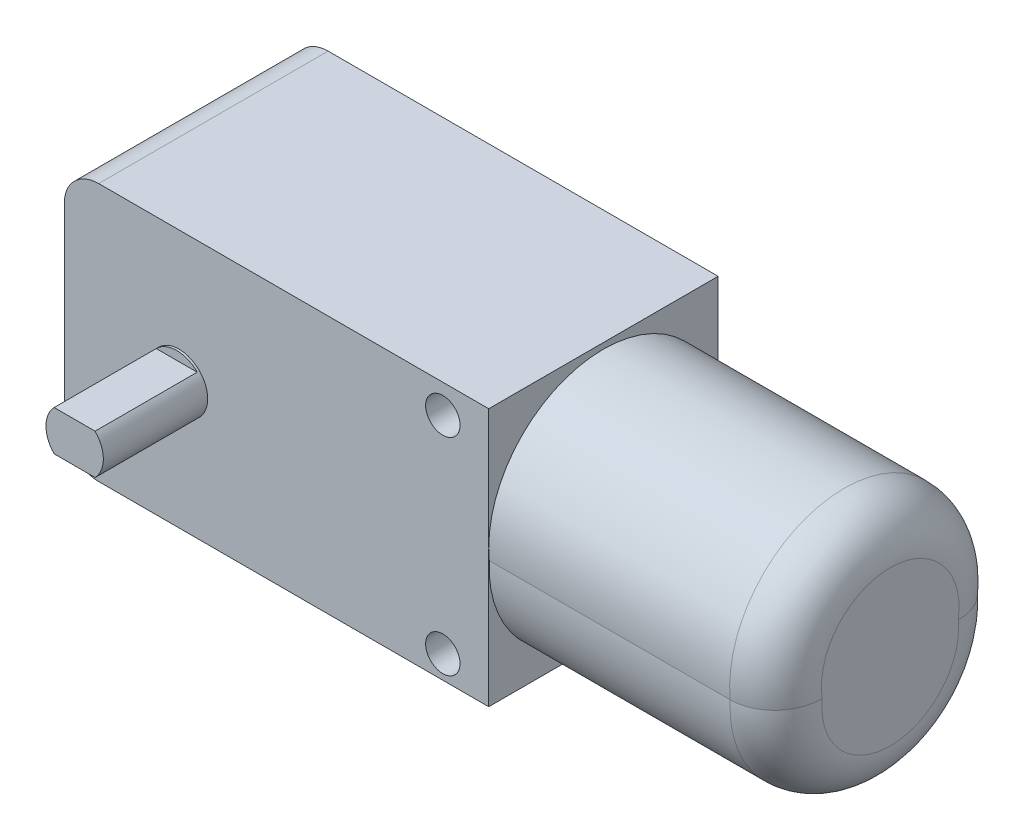
from build123d import *

# Parameters (mm, degrees)
SKETCH1_W           = 37
SKETCH1_H           = 22.5
BOSS_EXTRUDE1_DEPTH = 20
BOSS_EXTRUDE2_DEPTH = 25
SKETCH3_R           = 2.5
BOSS_EXTRUDE3_DEPTH = 9.1
SKETCH4_R           = 2.5
BOSS_EXTRUDE4_DEPTH = 9.1
FILLET1_R           = 3
FILLET2_R           = 4
SKETCH5_W           = 2.75
SKETCH5_H           = 5
BOSS_EXTRUDE5_DEPTH = 5
SKETCH6_R           = 1.5
CUT_EXTRUDE1_DEPTH  = 2.75
SKETCH7_R           = 1.5
CUT_EXTRUDE2_DEPTH  = 30.1
SKETCH8_W           = 8.509980697
SKETCH8_H           = 2.764975678
SKETCH8_W_2         = 9.677414873
SKETCH8_H_2         = 2.427034206
CUT_EXTRUDE3_DEPTH  = 8.9
SKETCH9_W           = 9.677414873
SKETCH9_H           = 2.427034206
SKETCH9_W_2         = 8.509980697
SKETCH9_H_2         = 2.764975678
CUT_EXTRUDE4_DEPTH  = 8.9


with BuildPart() as part:
    # Sketch1 → Boss-Extrude1 (new body)
    with BuildSketch(Plane.XY):
        with Locations((-45.764100782, -13.75)):
            Rectangle(SKETCH1_W, SKETCH1_H)
    extrude(amount=-BOSS_EXTRUDE1_DEPTH)

    # Sketch2 → Boss-Extrude2 (add)
    with BuildSketch(Plane(origin=(-27.264100782, 0, 0), x_dir=(0, 0, -1), z_dir=(1, 0, 0))):
        with BuildLine():
            ThreePointArc((0.050125629, -14), (10, -24.462429423), (19.949874371, -14))
            ThreePointArc((19.949874371, -14), (10, -3), (0.050125629, -14))
        make_face()
    extrude(amount=BOSS_EXTRUDE2_DEPTH)

    # Sketch3 → Boss-Extrude3 (add)
    with BuildSketch(Plane.XY):
        with Locations((-54.264100782, -14)):
            Circle(SKETCH3_R)
    extrude(amount=BOSS_EXTRUDE3_DEPTH)

    # Sketch4 → Boss-Extrude4 (add)
    with BuildSketch(Plane(origin=(0, 0, -20), x_dir=(-1, 0, 0), z_dir=(0, 0, -1))):
        with Locations((54.264100782, -14)):
            Circle(SKETCH4_R)
    extrude(amount=BOSS_EXTRUDE4_DEPTH)

    # Fillet1
    fillet1_edges = [part.edges().sort_by_distance(p)[0] for p in [
        (-64.264100782, -2.5, -10),
        (-64.264100782, -25, -10),
    ]]
    fillet(fillet1_edges, radius=FILLET1_R)

    # Fillet2
    fillet2_edges = [part.edges().sort_by_distance(p)[0] for p in [
        (-2.264100782, -3, -10),
        (-2.264100782, -24.462429423, -10),
    ]]
    fillet(fillet2_edges, radius=FILLET2_R)

    # Sketch5 → Boss-Extrude5 (add)
    with BuildSketch(Plane.ZY.offset(64.264100782)):
        with Locations((-10, -13.75)):
            Rectangle(SKETCH5_W, SKETCH5_H)
    extrude(amount=BOSS_EXTRUDE5_DEPTH)

    # Sketch6 → Cut-Extrude1 (cut)
    with BuildSketch(Plane(origin=(0, 0, -11.375), x_dir=(-1, 0, 0), z_dir=(0, 0, -1))):
        with Locations((66.764100782, -13.75)):
            Circle(SKETCH6_R)
    extrude(amount=-CUT_EXTRUDE1_DEPTH, mode=Mode.SUBTRACT)

    # Sketch7 → Cut-Extrude2 (cut, through all)
    with BuildSketch(Plane(origin=(0, 0, -20), x_dir=(-1, 0, 0), z_dir=(0, 0, -1))):
        with Locations((31.264100782, -5)):
            Circle(SKETCH7_R)
        with Locations((31.264100782, -23)):
            Circle(SKETCH7_R)
    extrude(amount=-CUT_EXTRUDE2_DEPTH, mode=Mode.SUBTRACT)

    # Sketch8 → Cut-Extrude3 (cut)
    with BuildSketch(Plane(origin=(0, 0, -29.1), x_dir=(-1, 0, 0), z_dir=(0, 0, -1))):
        with Locations((54.477604306, -17.132487839)):
            Rectangle(SKETCH8_W, SKETCH8_H)
        with Locations((54.323994545, -11.036482897)):
            Rectangle(SKETCH8_W_2, SKETCH8_H_2)
    extrude(amount=-CUT_EXTRUDE3_DEPTH, mode=Mode.SUBTRACT)

    # Sketch9 → Cut-Extrude4 (cut)
    with BuildSketch(Plane.XY.offset(9.1)):
        with Locations((-54.323994545, -11.036482897)):
            Rectangle(SKETCH9_W, SKETCH9_H)
        with Locations((-54.477604306, -17.132487839)):
            Rectangle(SKETCH9_W_2, SKETCH9_H_2)
    extrude(amount=-CUT_EXTRUDE4_DEPTH, mode=Mode.SUBTRACT)


solid = part.part
